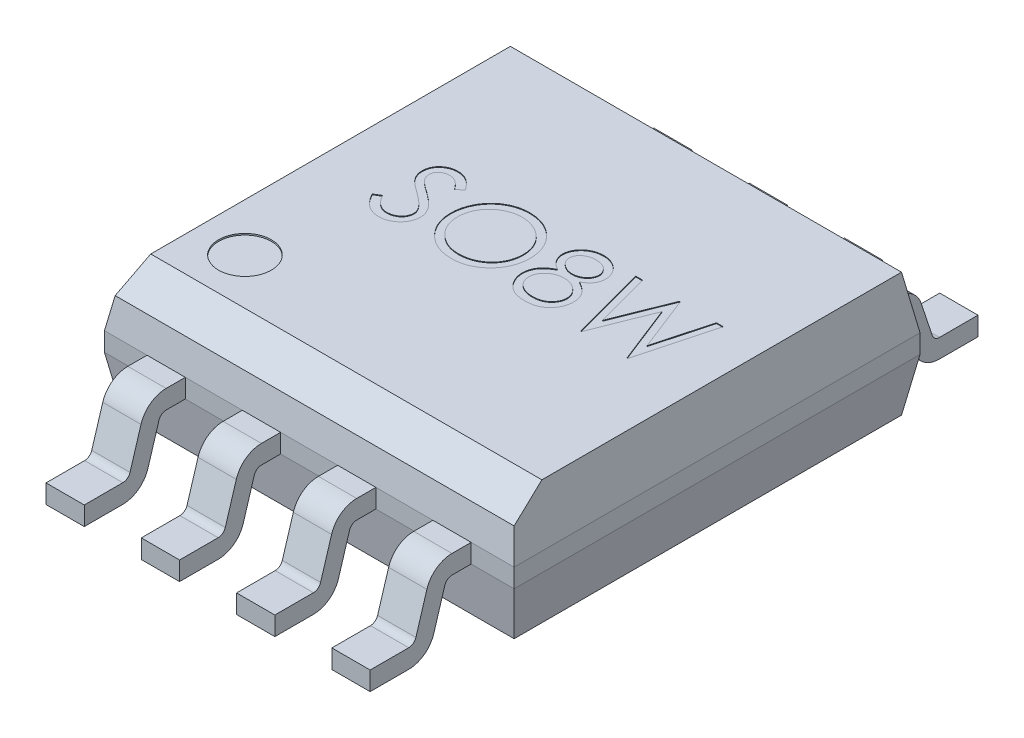
from build123d import *

# Parameters (mm, degrees)
SKETCH1_W                = 5.46
SKETCH1_H                = 5.41
BOSS_EXTRUDE1_DEPTH      = 0.125
BOSS_EXTRUDE1_DEPTH_BACK = 0.125
SKETCH2_W                = 5.46
SKETCH2_H                = 5.41
BOSS_EXTRUDE2_DEPTH      = 0.7
BOSS_EXTRUDE2_TAPER      = 10
SKETCH3_W                = 5.46
SKETCH3_H                = 5.41
BOSS_EXTRUDE3_DEPTH      = 0.7
BOSS_EXTRUDE3_TAPER      = 10
CHAMFER1_SIZE            = 0.3
CHAMFER1_SIZE2           = 0.369840916
BOSS_EXTRUDE4_START      = 0.3775
BOSS_EXTRUDE4_DEPTH      = 0.51
LPATTERN1_COUNT          = 2
LPATTERN1_PITCH          = 1.27
LPATTERN1_COL_COUNT      = 3
LPATTERN1_COL_PITCH      = 1.27
SKETCH6_R                = 0.351785146
CUT_EXTRUDE1_DEPTH       = 0.02
CUT_EXTRUDE2_DEPTH       = 0.01


with BuildPart() as part:
    # Sketch1 → Boss-Extrude1 (new, two sides)
    with BuildSketch(Plane(origin=(0, 0.92, 0), x_dir=(1, 0, 0), z_dir=(0, 1, 0))) as boss_extrude1_sk:
        Rectangle(SKETCH1_W, SKETCH1_H)
    extrude(amount=BOSS_EXTRUDE1_DEPTH)
    extrude(boss_extrude1_sk.sketch, amount=-BOSS_EXTRUDE1_DEPTH_BACK)

    # Sketch2 → Boss-Extrude2 (add)
    with BuildSketch(Plane(origin=(0, 1.045, 0), x_dir=(1, 0, 0), z_dir=(0, 1, 0))):
        Rectangle(SKETCH2_W, SKETCH2_H)
    extrude(amount=BOSS_EXTRUDE2_DEPTH, taper=BOSS_EXTRUDE2_TAPER)

    # Sketch3 → Boss-Extrude3 (add)
    with BuildSketch(Plane.XZ.offset(-0.795)):
        Rectangle(SKETCH3_W, SKETCH3_H)
    extrude(amount=BOSS_EXTRUDE3_DEPTH, taper=BOSS_EXTRUDE3_TAPER)

    # Chamfer1
    chamfer1_edges = [part.edges().sort_by_distance(p)[0] for p in [
        (0, 1.745, 2.581571114),
    ]]
    chamfer1_side = [part.faces().sort_by_distance(p)[0] for p in [
        (0, 1.392301631, 2.643761352),
    ]]
    chamfer(chamfer1_edges, length=CHAMFER1_SIZE, length2=CHAMFER1_SIZE2, reference=chamfer1_side[0])

    # Sketch5 → Boss-Extrude4 (add)
    with BuildSketch(Plane(origin=(0, 0, 0), x_dir=(0, 0, -1), z_dir=(1, 0, 0)).offset(BOSS_EXTRUDE4_START)):
        with BuildLine():
            ThreePointArc((-3.20280312, 0.243081155), (-3.329274491, 0.063778027), (-3.537635241, -0.005))
            Line((-3.537635241, -0.005), (-4.051646267, -0.005))
            Line((-4.051646267, -0.005), (-4.051646267, 0.245))
            Line((-4.051646267, 0.245), (-3.537635241, 0.245))
            ThreePointArc((-3.537635241, 0.245), (-3.478103598, 0.264650865), (-3.441968921, 0.31588033))
            Line((-3.441968921, 0.31588033), (-3.295422291, 0.796918845))
            ThreePointArc((-3.295422291, 0.796918845), (-3.168950919, 0.976221974), (-2.960590167, 1.045000002))
            Line((-2.960590167, 1.045000002), (-2.704999997, 1.045000002))
            Line((-2.704999997, 1.045000002), (-2.704999997, 0.794999999))
            Line((-2.704999997, 0.794999999), (-2.960590167, 0.794999999))
            ThreePointArc((-2.960590167, 0.794999999), (-3.020112307, 0.775356174), (-3.056249597, 0.724142296))
            Line((-3.056249597, 0.724142296), (-3.20280312, 0.243081155))
        make_face()
        with BuildLine():
            Line((2.704999997, 0.794999999), (2.960590167, 0.794999999))
            ThreePointArc((2.960590167, 0.794999999), (3.020112307, 0.775356174), (3.056249597, 0.724142296))
            Line((3.056249597, 0.724142296), (3.201156853, 0.288081155))
            ThreePointArc((3.201156853, 0.288081155), (3.327628224, 0.108778027), (3.535988974, 0.04))
            Line((3.535988974, 0.04), (4.05, 0.04))
            Line((4.05, 0.04), (4.05, 0.29))
            Line((4.05, 0.29), (3.535988974, 0.29))
            ThreePointArc((3.535988974, 0.29), (3.476457331, 0.309650865), (3.440322653, 0.36088033))
            Line((3.440322653, 0.36088033), (3.295422291, 0.796918845))
            ThreePointArc((3.295422291, 0.796918845), (3.168950919, 0.976221974), (2.960590167, 1.045000002))
            Line((2.960590167, 1.045000002), (2.704999997, 1.045000002))
            Line((2.704999997, 1.045000002), (2.704999997, 0.794999999))
        make_face()
    boss_extrude4 = extrude(amount=BOSS_EXTRUDE4_DEPTH)

    # LPattern1: Boss-Extrude4 ×2
    with Locations(*[(i * LPATTERN1_PITCH, 0, 0) for i in range(1, LPATTERN1_COUNT)]):
        add(boss_extrude4)

    # LPattern1 col: Boss-Extrude4 ×3
    with Locations(*[(-i * LPATTERN1_COL_PITCH, 0, 0) for i in range(1, LPATTERN1_COL_COUNT)]):
        add(boss_extrude4)

    # Sketch6 → Cut-Extrude1 (cut)
    with BuildSketch(Plane(origin=(0, 1.745, 0), x_dir=(1, 0, 0), z_dir=(0, 1, 0))):
        with Locations(Location((-1.967714846, -1.59473048, 0), (0, 0, 270))):
            Circle(SKETCH6_R)
    extrude(amount=-CUT_EXTRUDE1_DEPTH, mode=Mode.SUBTRACT)

    # Sketch7 → Cut-Extrude2 (cut)
    with BuildSketch(Plane(origin=(0, 1.745, 0), x_dir=(1, 0, 0), z_dir=(0, 1, 0))):
        with BuildLine():
            Line((-1.823125867, -0.042298986), (-1.738590611, 0.008382104))
            add(Edge.make_bspline(
                [(-1.738590611, 0.008382104), (-1.730728257, -0.004779149), (-1.715664291, -0.029995601), (-1.690535332, -0.064069327), (-1.664497357, -0.093029943), (-1.637357548, -0.116708974), (-1.609281562, -0.135351513), (-1.580086118, -0.148552151), (-1.549869601, -0.156785287), (-1.529305652, -0.157785311), (-1.519039329, -0.158284563)],
                knots=[0, 0, 0, 0, 1.272034388, 2.437168799, 3.508375237, 4.49857839, 5.41946034, 6.295179144, 7.148887113, 8, 8, 8, 8], degree=3))
            add(Edge.make_bspline(
                [(-1.519039329, -0.158284563), (-1.510271654, -0.15804037), (-1.492889719, -0.157556259), (-1.467300507, -0.152904601), (-1.442448563, -0.145758279), (-1.418846096, -0.135523727), (-1.396818777, -0.123141302), (-1.377502578, -0.108185252), (-1.360803689, -0.091440621), (-1.347143942, -0.072759863), (-1.336663932, -0.052669249), (-1.328609055, -0.032047549), (-1.324139034, -0.010570815), (-1.323465676, 0.003889317), (-1.323125867, 0.011186591)],
                knots=[0, 0, 0, 0, 1.095163259, 2.171163733, 3.241058638, 4.321873601, 5.38011039, 6.391990106, 7.366004449, 8.327778327, 9.272591725, 10.192022065, 11.087607919, 12, 12, 12, 12], degree=3))
            add(Edge.make_bspline(
                [(-1.323125867, 0.011186591), (-1.323547099, 0.019512548), (-1.324403401, 0.036438002), (-1.331640967, 0.061409332), (-1.343026466, 0.086121495), (-1.353530079, 0.101407571), (-1.358983239, 0.109343643)],
                knots=[0, 0, 0, 0, 0.938893495, 1.908633276, 2.914225137, 4, 4, 4, 4], degree=3))
            add(Edge.make_bspline(
                [(-1.358983239, 0.109343643), (-1.363460557, 0.115071306), (-1.372860127, 0.12709582), (-1.389019417, 0.144994459), (-1.407981163, 0.163456864), (-1.429096465, 0.183188024), (-1.45313449, 0.203270251), (-1.479342352, 0.224661188), (-1.508389168, 0.246547353), (-1.528760453, 0.261225228), (-1.539271701, 0.268798771)],
                knots=[0, 0, 0, 0, 0.722233717, 1.516239348, 2.393582979, 3.351407094, 4.387010283, 5.505090956, 6.712668013, 8, 8, 8, 8], degree=3))
            add(Edge.make_bspline(
                [(-1.539271701, 0.268798771), (-1.549792842, 0.276292653), (-1.569908464, 0.290620385), (-1.598039488, 0.311884466), (-1.623195049, 0.331325572), (-1.645263339, 0.349126718), (-1.664234652, 0.365290319), (-1.680258484, 0.379661159), (-1.692926643, 0.392627891), (-1.699971095, 0.401039703), (-1.70313388, 0.404816399)],
                knots=[0, 0, 0, 0, 1.452282411, 2.77665338, 3.964542531, 5.026858415, 5.96415736, 6.766646006, 7.446254459, 8, 8, 8, 8], degree=3))
            add(Edge.make_bspline(
                [(-1.70313388, 0.404816399), (-1.707554607, 0.410702409), (-1.716248561, 0.422278039), (-1.727724562, 0.440370856), (-1.737478609, 0.458891789), (-1.745124989, 0.477890607), (-1.751563909, 0.497100587), (-1.755894746, 0.516772371), (-1.758606574, 0.536817691), (-1.758884284, 0.550307262), (-1.759023303, 0.557059989)],
                knots=[0, 0, 0, 0, 1.068054152, 2.10047183, 3.106115577, 4.101338837, 5.06977816, 6.043150881, 7.020423561, 8, 8, 8, 8], degree=3))
            add(Edge.make_bspline(
                [(-1.759023303, 0.557059989), (-1.758650386, 0.567639924), (-1.757912523, 0.588573657), (-1.751672376, 0.619153894), (-1.741822977, 0.648350013), (-1.728024438, 0.675872966), (-1.710236623, 0.701006103), (-1.689652059, 0.724038528), (-1.665134491, 0.74340098), (-1.638233742, 0.760318711), (-1.608789064, 0.773560404), (-1.57793452, 0.783549255), (-1.545621071, 0.789209043), (-1.523734461, 0.790021262), (-1.512629072, 0.790433386)],
                knots=[0, 0, 0, 0, 1.005424448, 1.989358655, 2.955360095, 3.929531133, 4.905563448, 5.876582895, 6.856512386, 7.866279853, 8.892233794, 9.918561126, 10.94386622, 12, 12, 12, 12], degree=3))
            add(Edge.make_bspline(
                [(-1.512629072, 0.790433386), (-1.500845044, 0.790026943), (-1.477410372, 0.789218657), (-1.442939167, 0.782190791), (-1.409750391, 0.770562027), (-1.383052316, 0.757365268), (-1.362157241, 0.744184863), (-1.346222174, 0.732179199), (-1.330074331, 0.71835774), (-1.313583459, 0.702683669), (-1.297028984, 0.685013169), (-1.280165141, 0.665467258), (-1.262952493, 0.644165385), (-1.25187939, 0.628958385), (-1.24620279, 0.621162553)],
                knots=[0, 0, 0, 0, 1.286793592, 2.559021753, 3.825965368, 5.121522368, 5.803751409, 6.523245864, 7.299691795, 8.125521123, 9.008227632, 9.944561021, 10.946284179, 12, 12, 12, 12], degree=3))
            Line((-1.24620279, 0.621162553), (-1.327332598, 0.559664155))
            add(Edge.make_bspline(
                [(-1.327332598, 0.559664155), (-1.332231436, 0.56597521), (-1.341665452, 0.578128825), (-1.355988163, 0.595149201), (-1.369487776, 0.610696766), (-1.382787891, 0.624201089), (-1.395186071, 0.636401698), (-1.407219512, 0.646847343), (-1.418715041, 0.65564037), (-1.433205587, 0.665024245), (-1.451410649, 0.674326103), (-1.474263374, 0.682197268), (-1.498145166, 0.686927286), (-1.514410775, 0.687552682), (-1.522645098, 0.687869284)],
                knots=[0, 0, 0, 0, 1.181633172, 2.275549214, 3.290209073, 4.226197932, 5.078386478, 5.862611352, 6.581680152, 7.217281963, 8.414376989, 9.595101626, 10.782541182, 12, 12, 12, 12], degree=3))
            add(Edge.make_bspline(
                [(-1.522645098, 0.687869284), (-1.532975533, 0.687523084), (-1.552896804, 0.68685547), (-1.581179728, 0.679564045), (-1.606635135, 0.668083514), (-1.628507297, 0.65199352), (-1.646717862, 0.632930379), (-1.65989085, 0.610993563), (-1.667819468, 0.58677002), (-1.668786977, 0.569872404), (-1.669279713, 0.561266719)],
                knots=[0, 0, 0, 0, 1.14458467, 2.207223713, 3.21896685, 4.227309161, 5.202851033, 6.127160689, 7.046193047, 8, 8, 8, 8], degree=3))
            add(Edge.make_bspline(
                [(-1.669279713, 0.561266719), (-1.669167392, 0.555909154), (-1.668942564, 0.545185263), (-1.665806908, 0.529342), (-1.661778528, 0.51353876), (-1.655394919, 0.497846593), (-1.646581975, 0.481991062), (-1.635009068, 0.465699137), (-1.620433836, 0.44882722), (-1.609268975, 0.437853685), (-1.603374265, 0.432059989)],
                knots=[0, 0, 0, 0, 0.858281714, 1.717966888, 2.583508476, 3.4729293, 4.427298488, 5.488583878, 6.674047936, 8, 8, 8, 8], degree=3))
            add(Edge.make_bspline(
                [(-1.603374265, 0.432059989), (-1.601185301, 0.430106553), (-1.595984825, 0.425465636), (-1.586477417, 0.417867842), (-1.573922332, 0.408495621), (-1.558647418, 0.396899245), (-1.540371029, 0.383447399), (-1.519091155, 0.368312081), (-1.495045003, 0.35100195), (-1.477981599, 0.338899795), (-1.468959201, 0.332500694)],
                knots=[0, 0, 0, 0, 0.420754252, 0.999615792, 1.744751191, 2.668019286, 3.750313428, 4.999500688, 6.413464383, 8, 8, 8, 8], degree=3))
            add(Edge.make_bspline(
                [(-1.468959201, 0.332500694), (-1.458106083, 0.324603163), (-1.437090524, 0.309310688), (-1.407188358, 0.286334779), (-1.380075841, 0.263863988), (-1.355657783, 0.242041815), (-1.333692952, 0.221033788), (-1.314425032, 0.200587165), (-1.297657695, 0.18084843), (-1.279606489, 0.15554198), (-1.261161398, 0.12446167), (-1.245320967, 0.086382173), (-1.235332868, 0.048154653), (-1.234026721, 0.022461271), (-1.233382278, 0.009784348)],
                knots=[0, 0, 0, 0, 1.163667725, 2.253281268, 3.268753668, 4.215851969, 5.092017293, 5.902905408, 6.650798638, 7.335211899, 8.59617414, 9.77448103, 10.901945474, 12, 12, 12, 12], degree=3))
            add(Edge.make_bspline(
                [(-1.233382278, 0.009784348), (-1.233570031, 0.000819101), (-1.233941893, -0.016937295), (-1.23821644, -0.043010174), (-1.244479201, -0.06833328), (-1.253918411, -0.092593597), (-1.265439313, -0.116234958), (-1.280058241, -0.138637215), (-1.297003294, -0.160296186), (-1.316441512, -0.180634327), (-1.33771177, -0.199304669), (-1.360192826, -0.215912972), (-1.383921475, -0.229761064), (-1.408768994, -0.241061305), (-1.43474109, -0.249899453), (-1.461829029, -0.25630313), (-1.49007746, -0.260233333), (-1.509277598, -0.260641264), (-1.519039329, -0.260848665)],
                knots=[0, 0, 0, 0, 0.983748083, 1.948392443, 2.894712957, 3.844097841, 4.80183111, 5.778335162, 6.776009319, 7.81870978, 8.863265674, 9.881300176, 10.883814829, 11.87499822, 12.874611388, 13.892143829, 14.928324115, 16, 16, 16, 16], degree=3))
            add(Edge.make_bspline(
                [(-1.519039329, -0.260848665), (-1.526592284, -0.260702613), (-1.541603073, -0.260412349), (-1.563805782, -0.257846269), (-1.58555995, -0.254215668), (-1.606592602, -0.248451648), (-1.62717472, -0.241458226), (-1.647216787, -0.232847274), (-1.666728516, -0.222528073), (-1.685819254, -0.210729495), (-1.704440447, -0.19699871), (-1.722417438, -0.181006283), (-1.740340062, -0.163193282), (-1.757679318, -0.143075978), (-1.774785931, -0.120979383), (-1.791322619, -0.096696759), (-1.807631682, -0.070360372), (-1.817864672, -0.05182749), (-1.823125867, -0.042298986)],
                knots=[0, 0, 0, 0, 0.915332311, 1.819136955, 2.706846663, 3.586547465, 4.459518054, 5.340707479, 6.227863349, 7.133153174, 8.059268498, 9.028702269, 10.047606654, 11.120612155, 12.245963614, 13.433783089, 14.680604001, 16, 16, 16, 16], degree=3))
        make_face()
        with BuildLine():
            add(Edge.make_bspline(
                [(-0.560305354, 0.790433386), (-0.541788753, 0.789964392), (-0.505420619, 0.789043249), (-0.451970649, 0.781992076), (-0.400943478, 0.769793394), (-0.351923439, 0.753546827), (-0.305496874, 0.731874146), (-0.261314333, 0.705678389), (-0.219480941, 0.674685115), (-0.180560546, 0.639133907), (-0.144944275, 0.600452921), (-0.11356545, 0.559173518), (-0.087267652, 0.515545288), (-0.065671713, 0.469699337), (-0.048729253, 0.421739346), (-0.037038097, 0.371409631), (-0.029570054, 0.319036291), (-0.028696975, 0.28331433), (-0.028254072, 0.265193002)],
                knots=[0, 0, 0, 0, 1.065120563, 2.091984664, 3.0946048, 4.079830382, 5.057816894, 6.036188127, 7.030412546, 8.04752943, 9.064399622, 10.05169764, 11.02544977, 11.989514704, 12.962713494, 13.945757189, 14.957906945, 16, 16, 16, 16], degree=3))
            add(Edge.make_bspline(
                [(-0.028254072, 0.265193002), (-0.02869691, 0.24720516), (-0.029569795, 0.21174904), (-0.037046589, 0.159708056), (-0.048772589, 0.109682142), (-0.065514379, 0.061754813), (-0.087007373, 0.015875509), (-0.113480279, -0.027835049), (-0.144663482, -0.069391192), (-0.180151154, -0.108337667), (-0.218837166, -0.144051231), (-0.260331528, -0.175170909), (-0.303701048, -0.201949231), (-0.349503821, -0.223315995), (-0.397132403, -0.240393686), (-0.447013067, -0.252037295), (-0.498912082, -0.259547879), (-0.534303798, -0.260410312), (-0.552292534, -0.260848665)],
                knots=[0, 0, 0, 0, 1.043624062, 2.057103931, 3.04512605, 4.022047818, 4.998200453, 5.980619268, 6.982898556, 8.009068085, 9.034988726, 10.034168286, 11.015286542, 11.987931943, 12.962482838, 13.94673481, 14.956375938, 16, 16, 16, 16], degree=3))
            add(Edge.make_bspline(
                [(-0.552292534, -0.260848665), (-0.570413768, -0.260405983), (-0.606135544, -0.259533339), (-0.658574697, -0.252052938), (-0.708939767, -0.240355422), (-0.757086724, -0.223638441), (-0.803042418, -0.202033518), (-0.846896728, -0.175689409), (-0.888473627, -0.144430226), (-0.927428411, -0.108954062), (-0.96307104, -0.070333619), (-0.994145147, -0.028952403), (-1.020495179, 0.014377728), (-1.04202756, 0.05977702), (-1.059074548, 0.107026004), (-1.070704496, 0.156439855), (-1.078229054, 0.207736856), (-1.079096153, 0.242663399), (-1.079536124, 0.260385309)],
                knots=[0, 0, 0, 0, 1.053102029, 2.075944431, 3.073151272, 4.055350789, 5.033113405, 6.020478099, 7.024410459, 8.052272461, 9.079885166, 10.07527673, 11.055994387, 12.023226415, 12.992069828, 13.970394897, 14.97016774, 16, 16, 16, 16], degree=3))
            add(Edge.make_bspline(
                [(-1.079536124, 0.260385309), (-1.079383371, 0.272280358), (-1.079079792, 0.295920393), (-1.075425022, 0.331025136), (-1.070121679, 0.365565324), (-1.062521133, 0.399442737), (-1.052580657, 0.432574447), (-1.040851506, 0.465188951), (-1.026525836, 0.496955729), (-1.010331365, 0.52802527), (-0.992256563, 0.557913243), (-0.972292063, 0.586164552), (-0.9511391, 0.613016266), (-0.927949559, 0.637772552), (-0.903487718, 0.661153597), (-0.877356753, 0.682800088), (-0.849716111, 0.702907217), (-0.82044686, 0.721027314), (-0.79027021, 0.737415638), (-0.759162559, 0.751479024), (-0.727546396, 0.763549327), (-0.695273639, 0.77333242), (-0.66242999, 0.781055859), (-0.628943766, 0.786315103), (-0.594841644, 0.789979194), (-0.571866982, 0.790281337), (-0.560305354, 0.790433386)],
                knots=[0, 0, 0, 0, 1.037015668, 2.060948919, 3.074880161, 4.083647147, 5.086022904, 6.090072063, 7.104153813, 8.122640571, 9.144368836, 10.147691507, 11.138137339, 12.123020368, 13.103399296, 14.087645067, 15.080126199, 16.082011238, 17.087798457, 18.072939717, 19.057185487, 20.037253025, 21.01195951, 21.997135196, 22.992090687, 24, 24, 24, 24], degree=3))
        make_face()
        with BuildLine():
            add(Edge.make_bspline(
                [(-0.555898303, 0.687869284), (-0.565388198, 0.687753601), (-0.584277265, 0.687523341), (-0.612358561, 0.684490279), (-0.640070542, 0.680167454), (-0.667418931, 0.674001305), (-0.6942893, 0.665600147), (-0.720932112, 0.655931316), (-0.747104413, 0.644153862), (-0.772719801, 0.630847375), (-0.797552679, 0.616119112), (-0.82098488, 0.599841464), (-0.843077064, 0.582396163), (-0.86377514, 0.563742495), (-0.883018332, 0.543785466), (-0.901185389, 0.522827627), (-0.917548127, 0.500269944), (-0.932544006, 0.476724113), (-0.945963389, 0.452220804), (-0.957896348, 0.427017986), (-0.967657493, 0.400910076), (-0.975618172, 0.374180317), (-0.982218118, 0.346871042), (-0.986399239, 0.318775086), (-0.989465627, 0.290033625), (-0.989682726, 0.270610238), (-0.989792534, 0.26078595)],
                knots=[0, 0, 0, 0, 1.008559885, 2.007477868, 2.99961109, 3.989939068, 4.984837346, 5.991145699, 7.001802488, 8.033829008, 9.059044045, 10.069351652, 11.065060232, 12.050310815, 13.029377138, 14.011219647, 14.996725999, 15.989392538, 16.977580475, 17.965360261, 18.951710183, 19.937753436, 20.929683414, 21.935841486, 22.955955122, 24, 24, 24, 24], degree=3))
            add(Edge.make_bspline(
                [(-0.989792534, 0.26078595), (-0.989428288, 0.246339601), (-0.988711703, 0.217919164), (-0.982438111, 0.176271123), (-0.97277469, 0.136245898), (-0.958529728, 0.098062496), (-0.940715267, 0.061392701), (-0.918707584, 0.026561814), (-0.892633559, -0.006439579), (-0.863015409, -0.037381084), (-0.830637493, -0.065622743), (-0.796256713, -0.090412288), (-0.760241396, -0.111386645), (-0.722497624, -0.128473809), (-0.683226899, -0.142013734), (-0.64217617, -0.151293343), (-0.599618896, -0.157400616), (-0.570610137, -0.157987117), (-0.555898303, -0.158284563)],
                knots=[0, 0, 0, 0, 1.032063989, 2.030389145, 3.003944642, 3.970395727, 4.937377036, 5.913328081, 6.909231446, 7.93887556, 8.970685674, 9.976071282, 10.964166581, 11.944589148, 12.933237628, 13.927779006, 14.949070134, 16, 16, 16, 16], degree=3))
            add(Edge.make_bspline(
                [(-0.555898303, -0.158284563), (-0.546009874, -0.158148704), (-0.526398149, -0.157879256), (-0.497228, -0.155165349), (-0.468583368, -0.150813386), (-0.440504431, -0.144547484), (-0.413023057, -0.136705425), (-0.386024541, -0.127388932), (-0.359796458, -0.11576573), (-0.334007933, -0.102923459), (-0.309323293, -0.088283414), (-0.285758855, -0.072558228), (-0.263908575, -0.055138622), (-0.243225983, -0.036762104), (-0.223903786, -0.017058148), (-0.206072648, 0.00394763), (-0.18979261, 0.026387818), (-0.174802426, 0.049897934), (-0.161430065, 0.074468292), (-0.149778894, 0.099762485), (-0.139894289, 0.125718231), (-0.131914716, 0.152372966), (-0.125661727, 0.179676065), (-0.121353179, 0.207664088), (-0.118339339, 0.236281043), (-0.118112174, 0.25563643), (-0.117997662, 0.265393322)],
                knots=[0, 0, 0, 0, 1.047197238, 2.076906641, 3.100256066, 4.114471768, 5.12198147, 6.126382909, 7.136867548, 8.15857795, 9.17633901, 10.174870724, 11.156907918, 12.133735059, 13.104061851, 14.077631395, 15.04955518, 16.038496417, 17.029181396, 18.010275684, 18.986308667, 19.968651475, 20.955262928, 21.950658345, 22.966943676, 24, 24, 24, 24], degree=3))
            add(Edge.make_bspline(
                [(-0.117997662, 0.265393322), (-0.118112266, 0.275083466), (-0.118339603, 0.294305652), (-0.121351739, 0.322723029), (-0.125666279, 0.35050966), (-0.131884196, 0.377556461), (-0.139898525, 0.403870326), (-0.14978062, 0.429426539), (-0.161433562, 0.454320309), (-0.174807341, 0.478490108), (-0.189840433, 0.501682891), (-0.20626736, 0.523855009), (-0.224371745, 0.544590077), (-0.243636324, 0.56439999), (-0.264542291, 0.582862244), (-0.286994946, 0.599982964), (-0.310721711, 0.616175328), (-0.335843779, 0.630782632), (-0.361770623, 0.644272413), (-0.388374611, 0.655829842), (-0.415354353, 0.665650448), (-0.442641243, 0.674026723), (-0.470464951, 0.680143303), (-0.498637473, 0.684494175), (-0.527119833, 0.687522285), (-0.546275038, 0.68775325), (-0.555898303, 0.687869284)],
                knots=[0, 0, 0, 0, 1.02996197, 2.043119294, 3.035359645, 4.018872909, 4.991431989, 5.957985074, 6.929999688, 7.912076566, 8.892894881, 9.867085534, 10.843653904, 11.817741046, 12.803660682, 13.806313499, 14.818574707, 15.856120519, 16.894564902, 17.924820532, 18.937903209, 19.946497019, 20.957711757, 21.963978472, 22.977135795, 24, 24, 24, 24], degree=3))
        make_face(mode=Mode.SUBTRACT)
        with BuildLine():
            add(Edge.make_bspline(
                [(0.573308428, 0.321883707), (0.581493727, 0.317615719), (0.597457794, 0.309291718), (0.620194139, 0.295888625), (0.640972711, 0.281762635), (0.660370014, 0.267580961), (0.678045257, 0.252800489), (0.693800804, 0.237362444), (0.708025838, 0.221652174), (0.720433491, 0.205403648), (0.731346873, 0.188660034), (0.740778911, 0.171377385), (0.748840969, 0.153593575), (0.75523038, 0.135114481), (0.760493749, 0.116211549), (0.764115351, 0.096640697), (0.766063041, 0.076530885), (0.766431274, 0.062939942), (0.766617722, 0.056058386)],
                knots=[0, 0, 0, 0, 1.272397273, 2.481599622, 3.635517121, 4.734568067, 5.792894095, 6.808321871, 7.773003508, 8.711915296, 9.623354172, 10.525449501, 11.423591555, 12.311487226, 13.218079475, 14.126165749, 15.051214107, 16, 16, 16, 16], degree=3))
            add(Edge.make_bspline(
                [(0.766617722, 0.056058386), (0.766397317, 0.046430463), (0.765961051, 0.027373189), (0.762161055, -0.000754271), (0.756471633, -0.028071923), (0.748163201, -0.054573778), (0.737387946, -0.080113599), (0.72410885, -0.104713248), (0.709077077, -0.128775908), (0.697005009, -0.143581451), (0.690896569, -0.151073024)],
                knots=[0, 0, 0, 0, 1.025265484, 2.029385089, 3.018602448, 3.995076438, 4.983346944, 5.966715145, 6.97116228, 8, 8, 8, 8], degree=3))
            add(Edge.make_bspline(
                [(0.690896569, -0.151073024), (0.68294329, -0.159814102), (0.667135014, -0.177188243), (0.640054178, -0.199745617), (0.61033364, -0.218702587), (0.578088402, -0.2341517), (0.543404659, -0.246176231), (0.5062898, -0.25481695), (0.466671471, -0.259766216), (0.439441336, -0.260481642), (0.425471889, -0.260848665)],
                knots=[0, 0, 0, 0, 0.954267603, 1.896743057, 2.838368354, 3.796610408, 4.779680527, 5.799409237, 6.871065594, 8, 8, 8, 8], degree=3))
            add(Edge.make_bspline(
                [(0.425471889, -0.260848665), (0.412039492, -0.260519386), (0.385901413, -0.259878641), (0.347856305, -0.255537375), (0.312392571, -0.247929413), (0.279304008, -0.237516668), (0.248790096, -0.223970888), (0.220937781, -0.207111343), (0.195345218, -0.187616645), (0.172789082, -0.164926909), (0.152763813, -0.140624659), (0.13517294, -0.115552771), (0.120551775, -0.089708954), (0.108172605, -0.063478564), (0.098696027, -0.036493948), (0.092132538, -0.008893945), (0.087964163, 0.019273239), (0.087409553, 0.038282283), (0.087130543, 0.047845245)],
                knots=[0, 0, 0, 0, 1.256902934, 2.445805442, 3.576955095, 4.645999104, 5.686449165, 6.692658513, 7.68621702, 8.689161843, 9.678783111, 10.630372946, 11.551080876, 12.453998257, 13.34127905, 14.221779781, 15.105423033, 16, 16, 16, 16], degree=3))
            add(Edge.make_bspline(
                [(0.087130543, 0.047845245), (0.087295652, 0.054862157), (0.087621965, 0.068730052), (0.089880493, 0.089218431), (0.093511482, 0.109160184), (0.098442756, 0.128628968), (0.105125906, 0.147483046), (0.113195087, 0.165811753), (0.122604216, 0.183635781), (0.133484549, 0.201052604), (0.14614227, 0.217818179), (0.160474742, 0.234217035), (0.176768418, 0.249994711), (0.194842035, 0.265343975), (0.214489046, 0.280537111), (0.236219769, 0.294753033), (0.259458132, 0.308998166), (0.275973962, 0.31751483), (0.284446248, 0.321883707)],
                knots=[0, 0, 0, 0, 0.941657376, 1.861047343, 2.762797495, 3.66048619, 4.553285746, 5.444104102, 6.34607688, 7.256116206, 8.197091036, 9.162375105, 10.176350973, 11.237807142, 12.343728897, 13.50695164, 14.721116704, 16, 16, 16, 16], degree=3))
            add(Edge.make_bspline(
                [(0.284446248, 0.321883707), (0.272848712, 0.328207926), (0.250392637, 0.340453386), (0.220658511, 0.362952473), (0.195118333, 0.38732042), (0.174474128, 0.41407179), (0.15822492, 0.442370897), (0.147076747, 0.472040683), (0.139534895, 0.502531002), (0.138787801, 0.523361343), (0.138412594, 0.533822809)],
                knots=[0, 0, 0, 0, 1.166880483, 2.259407225, 3.286803203, 4.280235371, 5.237608625, 6.161067461, 7.076446754, 8, 8, 8, 8], degree=3))
            add(Edge.make_bspline(
                [(0.138412594, 0.533822809), (0.138879858, 0.544479254), (0.13981914, 0.565900568), (0.147414375, 0.597788032), (0.159791537, 0.62910705), (0.176626107, 0.659705825), (0.197593883, 0.688548744), (0.222750039, 0.714417586), (0.251493838, 0.737078009), (0.2836818, 0.756099773), (0.318320725, 0.771580818), (0.354868075, 0.782260368), (0.392687073, 0.789242115), (0.418429278, 0.790032588), (0.431481505, 0.790433386)],
                knots=[0, 0, 0, 0, 0.888701115, 1.786444228, 2.72001202, 3.692817113, 4.693886446, 5.687152267, 6.695133018, 7.739871481, 8.800368666, 9.853104506, 10.91144658, 12, 12, 12, 12], degree=3))
            add(Edge.make_bspline(
                [(0.431481505, 0.790433386), (0.44419688, 0.790020145), (0.469270153, 0.789205281), (0.50612576, 0.78240903), (0.541390011, 0.771057739), (0.574941297, 0.755658532), (0.606178973, 0.736690835), (0.633779633, 0.713719157), (0.65816037, 0.687964428), (0.67832734, 0.659130256), (0.694945309, 0.628649057), (0.706516995, 0.596756909), (0.713931844, 0.564142892), (0.714867091, 0.542074891), (0.715335671, 0.531018322)],
                knots=[0, 0, 0, 0, 1.072916533, 2.115669174, 3.151510826, 4.193348718, 5.225979165, 6.227137561, 7.216255879, 8.211077061, 9.189680878, 10.138522389, 11.067357538, 12, 12, 12, 12], degree=3))
            add(Edge.make_bspline(
                [(0.715335671, 0.531018322), (0.714925797, 0.520167847), (0.714120827, 0.49885813), (0.707349415, 0.46779341), (0.695945611, 0.438701398), (0.680375851, 0.411251984), (0.660082854, 0.385942984), (0.635337502, 0.362452564), (0.606337079, 0.340587756), (0.584548255, 0.328248795), (0.573308428, 0.321883707)],
                knots=[0, 0, 0, 0, 0.975232327, 1.915300861, 2.843280834, 3.77672583, 4.742871857, 5.749627742, 6.839139064, 8, 8, 8, 8], degree=3))
        make_face()
        with BuildLine():
            add(Edge.make_bspline(
                [(0.426473492, 0.687869284), (0.419458976, 0.687683158), (0.405735515, 0.687319014), (0.385613038, 0.685416546), (0.366478076, 0.681715627), (0.348130704, 0.676790281), (0.330822472, 0.67013657), (0.314318314, 0.662309425), (0.298899117, 0.652793406), (0.284378744, 0.642118778), (0.271307094, 0.630377948), (0.259705794, 0.618145457), (0.25006919, 0.605181059), (0.241886016, 0.591807242), (0.235948439, 0.577627077), (0.231501495, 0.563075313), (0.228495384, 0.54796806), (0.228270129, 0.537643343), (0.228156184, 0.532420566)],
                knots=[0, 0, 0, 0, 1.203892937, 2.355340988, 3.463153438, 4.544400666, 5.610487187, 6.640501085, 7.674077295, 8.714426146, 9.728707835, 10.68524104, 11.601827946, 12.495867327, 13.368432065, 14.231010473, 15.105153427, 16, 16, 16, 16], degree=3))
            add(Edge.make_bspline(
                [(0.228156184, 0.532420566), (0.228352575, 0.527197563), (0.22874067, 0.516876159), (0.231742136, 0.501634483), (0.236215523, 0.486656873), (0.243258569, 0.47229947), (0.2517061, 0.458064224), (0.262132236, 0.444306914), (0.274557672, 0.430979661), (0.288565512, 0.418195821), (0.303825952, 0.406224745), (0.319992821, 0.395832408), (0.336863219, 0.387136948), (0.35426381, 0.379899975), (0.372371938, 0.374274279), (0.391076645, 0.370283237), (0.410381074, 0.367802666), (0.42346124, 0.367506374), (0.430079261, 0.367356463)],
                knots=[0, 0, 0, 0, 0.873023192, 1.725219244, 2.590779336, 3.480155217, 4.391973325, 5.357036234, 6.360879153, 7.436073238, 8.526419356, 9.601555421, 10.645666583, 11.697338044, 12.750135903, 13.812665442, 14.89329948, 16, 16, 16, 16], degree=3))
            add(Edge.make_bspline(
                [(0.430079261, 0.367356463), (0.438579291, 0.367605854), (0.455495396, 0.368102172), (0.480432348, 0.372716793), (0.504678817, 0.379975626), (0.527975647, 0.389907045), (0.549719814, 0.402372148), (0.569102691, 0.417295868), (0.585958946, 0.43433361), (0.600113406, 0.453220134), (0.611087648, 0.473320588), (0.619631022, 0.4934921), (0.62461994, 0.51394988), (0.625270674, 0.527654727), (0.625592081, 0.534423771)],
                knots=[0, 0, 0, 0, 1.076279235, 2.141928126, 3.20205304, 4.278698113, 5.344010996, 6.36967002, 7.368914609, 8.37248503, 9.349703398, 10.264243087, 11.142681841, 12, 12, 12, 12], degree=3))
            add(Edge.make_bspline(
                [(0.625592081, 0.534423771), (0.625440111, 0.539174638), (0.625138471, 0.548604429), (0.62265274, 0.562529676), (0.618545359, 0.576138129), (0.612984479, 0.589542206), (0.605667395, 0.602553844), (0.596991913, 0.615377583), (0.586453484, 0.627724944), (0.574625932, 0.639883672), (0.561212958, 0.651136251), (0.546240411, 0.661031882), (0.529785054, 0.669435413), (0.511846497, 0.676260771), (0.492490804, 0.681387157), (0.471807126, 0.685226113), (0.449622998, 0.687389859), (0.434357355, 0.687706009), (0.426473492, 0.687869284)],
                knots=[0, 0, 0, 0, 0.814439003, 1.616544685, 2.417341072, 3.248991801, 4.09997495, 4.973547432, 5.9003056, 6.880240646, 7.880314356, 8.896779544, 9.951930927, 11.043077905, 12.18215768, 13.381699519, 14.647792085, 16, 16, 16, 16], degree=3))
        make_face(mode=Mode.SUBTRACT)
        with BuildLine():
            add(Edge.make_bspline(
                [(0.432282787, 0.264792361), (0.423389705, 0.264634177), (0.405943649, 0.26432386), (0.380384527, 0.260869717), (0.355855051, 0.256061319), (0.332437926, 0.248766794), (0.310143041, 0.239282083), (0.288849703, 0.227872214), (0.268720809, 0.214384945), (0.250034316, 0.198991626), (0.232970507, 0.18240321), (0.217999565, 0.1648426), (0.205285987, 0.146636162), (0.195047916, 0.127552668), (0.186644564, 0.107996208), (0.181126313, 0.087479752), (0.177588681, 0.06639772), (0.177113644, 0.052066263), (0.176874133, 0.044840437)],
                knots=[0, 0, 0, 0, 1.140299081, 2.23698856, 3.303958914, 4.344563908, 5.37730929, 6.408454204, 7.439741482, 8.480804886, 9.510774543, 10.48932336, 11.43758569, 12.353841022, 13.263987381, 14.161954604, 15.073269652, 16, 16, 16, 16], degree=3))
            add(Edge.make_bspline(
                [(0.176874133, 0.044840437), (0.177263635, 0.035860179), (0.178036399, 0.018043555), (0.184166867, -0.008288751), (0.194005592, -0.033780481), (0.207727082, -0.058223896), (0.224717817, -0.081066784), (0.245611094, -0.100977863), (0.269108476, -0.118669714), (0.296005006, -0.132978437), (0.325384567, -0.144405539), (0.357239347, -0.152278671), (0.391112181, -0.157490514), (0.414500636, -0.158015709), (0.426473492, -0.158284563)],
                knots=[0, 0, 0, 0, 0.898778495, 1.783155532, 2.693654817, 3.627872908, 4.583023416, 5.533784346, 6.509005473, 7.520592997, 8.575161974, 9.658835044, 10.801527049, 12, 12, 12, 12], degree=3))
            add(Edge.make_bspline(
                [(0.426473492, -0.158284563), (0.43583074, -0.158104903), (0.454061659, -0.157754869), (0.480657645, -0.15466507), (0.505756087, -0.149765177), (0.529308315, -0.14263845), (0.551577984, -0.133938457), (0.572187514, -0.122746434), (0.591667093, -0.110017198), (0.609056842, -0.094914868), (0.624894902, -0.078777869), (0.638704414, -0.061695), (0.650692286, -0.044130534), (0.66010113, -0.025687538), (0.667622917, -0.006719848), (0.673029647, 0.012947441), (0.676365708, 0.03337465), (0.676703107, 0.047231528), (0.676874133, 0.054255502)],
                knots=[0, 0, 0, 0, 1.224942928, 2.386581632, 3.501229538, 4.569074225, 5.605009692, 6.626002462, 7.634866581, 8.645888296, 9.63523824, 10.59253846, 11.518950513, 12.414518923, 13.29783783, 14.186679152, 15.080837789, 16, 16, 16, 16], degree=3))
            add(Edge.make_bspline(
                [(0.676874133, 0.054255502), (0.676615319, 0.061077599), (0.676104983, 0.074529583), (0.672865928, 0.094462876), (0.667175678, 0.113720823), (0.65936785, 0.132535111), (0.648973289, 0.150524525), (0.636731898, 0.168157717), (0.62196215, 0.184945273), (0.605272837, 0.201017586), (0.587084562, 0.215879225), (0.567751092, 0.229026207), (0.547421246, 0.24009824), (0.526138043, 0.249102953), (0.503948741, 0.256185088), (0.480869661, 0.261132515), (0.456873783, 0.264246687), (0.440572391, 0.264608414), (0.432282787, 0.264792361)],
                knots=[0, 0, 0, 0, 0.917430815, 1.809013306, 2.70690318, 3.612392954, 4.541220862, 5.495268465, 6.494511384, 7.542276156, 8.608045339, 9.649016899, 10.681629292, 11.715607085, 12.752076957, 13.808767841, 14.885711793, 16, 16, 16, 16], degree=3))
        make_face(mode=Mode.SUBTRACT)
        Polygon((0.882002338, 0.764792361), (0.974750735, 0.764792361), (1.170463876, 0.031418963), (1.461529581, 0.764792361), (1.474550415, 0.764792361), (1.760207466, 0.036426976), (1.95692221, 0.764792361), (2.048669005, 0.764792361), (1.779037594, -0.235207639), (1.766217081, -0.235207639), (1.465335671, 0.529616078), (1.160848492, -0.235207639), (1.148027979, -0.235207639), align=None)
    extrude(amount=-CUT_EXTRUDE2_DEPTH, mode=Mode.SUBTRACT)


solid = part.part
